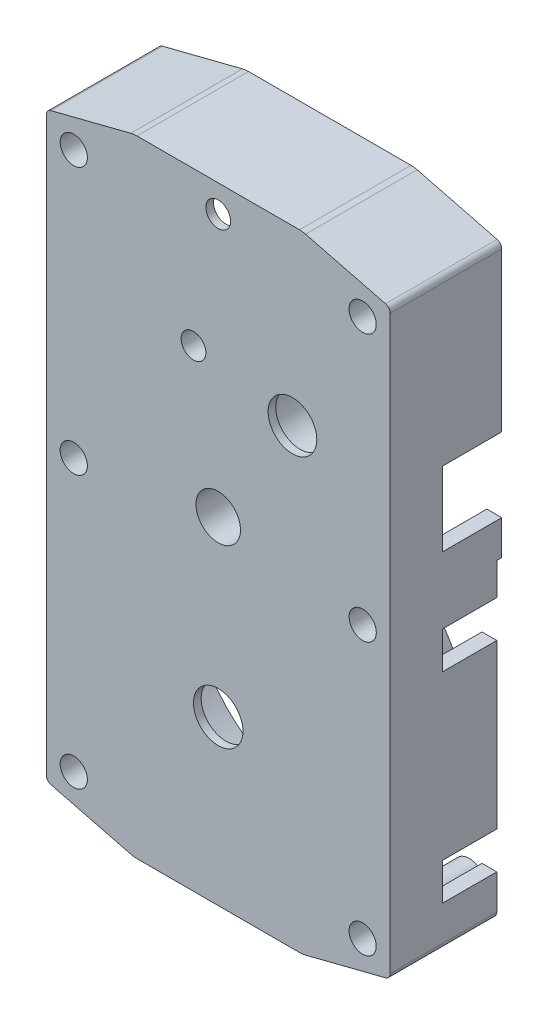
from build123d import *

# Parameters (mm, degrees)
BOSS_EXTRUDE1_DEPTH = 4.51
CUT_EXTRUDE1_DEPTH  = 4.2
SKETCH6_R           = 0.65
BOSS_EXTRUDE2_DEPTH = 4.2
SKETCH7_R           = 0.55
CUT_EXTRUDE2_DEPTH  = 4.6
SKETCH8_R           = 0.5
CUT_EXTRUDE3_DEPTH  = 3.5
SKETCH10_R          = 0.5
SKETCH10_R_2        = 0.985
SKETCH10_R_3        = 0.9
SKETCH10_R_4        = 1
SKETCH10_R_5        = 0.75
CUT_EXTRUDE4_DEPTH  = 10
SKETCH16_W          = 2.4
SKETCH16_H          = 3
SKETCH16_H_2        = 1.5
CUT_EXTRUDE5_DEPTH  = 0.6
SKETCH18_W          = 1.5
SKETCH18_H          = 2.4
CUT_EXTRUDE6_DEPTH  = 1
SKETCH21_W          = 2.4
SKETCH21_H          = 1.5
SKETCH21_W_2        = 1.5
SKETCH21_H_2        = 8.25
CUT_EXTRUDE7_DEPTH  = 0.6
SKETCH22_R          = 1.3
SKETCH22_R_2        = 0.9
BOSS_EXTRUDE3_DEPTH = 4.25
SKETCH23_R          = 5.9
SKETCH23_R_2        = 5.5
BOSS_EXTRUDE4_DEPTH = 4
SKETCH24_R          = 1.6
SKETCH24_R_2        = 1.2
SKETCH24_R_3        = 1.25
SKETCH24_R_4        = 0.5
BOSS_EXTRUDE5_DEPTH = 3.75
SKETCH26_R          = 0.75
BOSS_EXTRUDE6_DEPTH = 4.51
SKETCH27_R          = 0.675
BOSS_EXTRUDE7_DEPTH = 4.6
BOSS_EXTRUDE8_DEPTH = 1.25
SKETCH29_W          = 0.2
SKETCH29_H          = 13.4
CUT_EXTRUDE8_DEPTH  = 15


with BuildPart() as part:
    # Sketch4 → Boss-Extrude1 (new body)
    with BuildSketch(Plane.XY):
        with BuildLine():
            ThreePointArc((-13.711599695, 0.852101617), (-13.847357447, 0.940933533), (-13.9, 1.09439375))
            Line((-13.9, 1.09439375), (-13.9, 24.20560625))
            ThreePointArc((-13.9, 24.20560625), (-13.847357447, 24.359066467), (-13.711599695, 24.447898383))
            Line((-13.711599695, 24.447898383), (-10.481270444, 25.269168531))
            ThreePointArc((-10.481270444, 25.269168531), (-10.359031781, 25.292262196), (-10.234871665, 25.3))
            Line((-10.234871665, 25.3), (-3.665128335, 25.3))
            ThreePointArc((-3.665128335, 25.3), (-3.540968219, 25.292262196), (-3.418729556, 25.269168531))
            Line((-3.418729556, 25.269168531), (-0.188400305, 24.447898383))
            ThreePointArc((-0.188400305, 24.447898383), (-0.052642553, 24.359066467), (0, 24.20560625))
            Line((0, 24.20560625), (0, 1.09439375))
            ThreePointArc((0, 1.09439375), (-0.052642553, 0.940933533), (-0.188400305, 0.852101617))
            Line((-0.188400305, 0.852101617), (-3.418729556, 0.030831469))
            ThreePointArc((-3.418729556, 0.030831469), (-3.540968219, 0.007737804), (-3.665128335, 0))
            Line((-3.665128335, 0), (-10.234871665, 0))
            ThreePointArc((-10.234871665, 0), (-10.359031781, 0.007737804), (-10.481270444, 0.030831469))
            Line((-10.481270444, 0.030831469), (-13.711599695, 0.852101617))
        make_face()
    extrude(amount=BOSS_EXTRUDE1_DEPTH)

    # Sketch5 → Cut-Extrude1 (cut)
    with BuildSketch(Plane(origin=(0, 0, 0), x_dir=(-1, 0, 0), z_dir=(0, 0, -1))):
        with BuildLine():
            Line((13.3, 1.366545), (13.3, 23.933455))
            Line((13.3, 23.933455), (10.333431177, 24.687667412))
            ThreePointArc((10.333431177, 24.687667412), (10.284535712, 24.696904878), (10.234871665, 24.7))
            Line((10.234871665, 24.7), (3.665128335, 24.7))
            ThreePointArc((3.665128335, 24.7), (3.615464288, 24.696904878), (3.566568823, 24.687667412))
            Line((3.566568823, 24.687667412), (0.6, 23.933455))
            Line((0.6, 23.933455), (0.6, 1.366545))
            Line((0.6, 1.366545), (3.566568823, 0.612332588))
            ThreePointArc((3.566568823, 0.612332588), (3.615464288, 0.603095122), (3.665128335, 0.6))
            Line((3.665128335, 0.6), (10.234871665, 0.6))
            ThreePointArc((10.234871665, 0.6), (10.284535712, 0.603095122), (10.333431177, 0.612332588))
            Line((10.333431177, 0.612332588), (13.3, 1.366545))
        make_face()
    extrude(amount=-CUT_EXTRUDE1_DEPTH, mode=Mode.SUBTRACT)

    # Sketch6 → Boss-Extrude2 (add)
    with BuildSketch(Plane(origin=(0, 0, 4.2), x_dir=(-1, 0, 0), z_dir=(0, 0, -1))):
        with Locations((1.112347538, 1.766545)):
            Circle(SKETCH6_R)
        with Locations((1.112347538, 23.533455)):
            Circle(SKETCH6_R)
        with Locations((1.11, 12.75)):
            Circle(SKETCH6_R)
        with Locations((12.787652462, 23.533455)):
            Circle(SKETCH6_R)
        with Locations((12.787652462, 1.766545)):
            Circle(SKETCH6_R)
        with Locations((12.79, 12.75)):
            Circle(SKETCH6_R)
    extrude(amount=BOSS_EXTRUDE2_DEPTH)

    # Sketch7 → Cut-Extrude2 (cut)
    with BuildSketch(Plane(origin=(0, 0, 0), x_dir=(-1, 0, 0), z_dir=(0, 0, -1))):
        with Locations((1.112347538, 1.766545)):
            Circle(SKETCH7_R)
        with Locations((1.11, 12.75)):
            Circle(SKETCH7_R)
        with Locations((1.112347538, 23.533455)):
            Circle(SKETCH7_R)
        with Locations(Location((12.787652462, 1.766545, 0), (0, 0, 180))):
            Circle(SKETCH7_R)
        with Locations(Location((12.787652462, 23.533455, 0), (0, 0, 180))):
            Circle(SKETCH7_R)
        with Locations(Location((12.79, 12.75, 0), (0, 0, 180))):
            Circle(SKETCH7_R)
    extrude(amount=-CUT_EXTRUDE2_DEPTH, mode=Mode.SUBTRACT)

    # Sketch8 → Cut-Extrude3 (cut)
    with BuildSketch(Plane(origin=(0, 0, 4.2), x_dir=(-1, 0, 0), z_dir=(0, 0, -1))):
        with Locations(Location((6.95, 24.2, 0), (0, 0, 90))):
            Circle(SKETCH8_R)
    extrude(amount=-CUT_EXTRUDE3_DEPTH, mode=Mode.SUBTRACT)

    # Sketch10 → Cut-Extrude4 (cut)
    with BuildSketch(Plane.XY.offset(4.51)):
        with Locations((-7.95, 19.1)):
            Circle(SKETCH10_R)
        with Locations((-3.95, 18.3)):
            Circle(SKETCH10_R_2)
        with Locations((-6.95, 13.6)):
            Circle(SKETCH10_R_3)
        with Locations((-6.95, 6.6)):
            Circle(SKETCH10_R_4)
        with Locations((-11.3, 17.35)):
            Circle(SKETCH10_R_5)
    extrude(amount=-CUT_EXTRUDE4_DEPTH, mode=Mode.SUBTRACT)

    # Sketch16 → Cut-Extrude5 (cut)
    with BuildSketch(Plane(origin=(0, 0, 0), x_dir=(0, 0, -1), z_dir=(1, 0, 0))):
        with Locations((-1.2, 16.3)):
            Rectangle(SKETCH16_W, SKETCH16_H)
        with Locations((-1.2, 11.35)):
            Rectangle(SKETCH16_W, SKETCH16_H_2)
        with Locations((-1.2, 3.25)):
            Rectangle(SKETCH16_W, SKETCH16_H_2)
    extrude(amount=-CUT_EXTRUDE5_DEPTH, mode=Mode.SUBTRACT)

    # Sketch18 → Cut-Extrude6 (cut)
    with BuildSketch(Plane(origin=(0, 0, 0), x_dir=(-1, 0, 0), z_dir=(0, -1, 0))):
        with Locations((2.95, -1.2)):
            Rectangle(SKETCH18_W, SKETCH18_H)
        with Locations((11.15, -1.2)):
            Rectangle(SKETCH18_W, SKETCH18_H)
    extrude(amount=-CUT_EXTRUDE6_DEPTH, mode=Mode.SUBTRACT)

    # Sketch21 → Cut-Extrude7 (cut)
    with BuildSketch(Plane.ZY.offset(13.9)):
        with Locations((1.2, 3.25)):
            Rectangle(SKETCH21_W, SKETCH21_H)
        with Locations((1.2, 11.35)):
            Rectangle(SKETCH21_W, SKETCH21_H)
        with Locations((0.75, 18.175)):
            Rectangle(SKETCH21_W_2, SKETCH21_H_2)
    extrude(amount=-CUT_EXTRUDE7_DEPTH, mode=Mode.SUBTRACT)

    # Sketch22 → Boss-Extrude3 (add)
    with BuildSketch(Plane(origin=(0, 0, 4.2), x_dir=(-1, 0, 0), z_dir=(0, 0, -1))):
        with Locations((6.95, 13.6)):
            Circle(SKETCH22_R)
        with Locations(Location((6.95, 13.6, 0), (0, 0, 180))):
            Circle(SKETCH22_R_2, mode=Mode.SUBTRACT)
    extrude(amount=BOSS_EXTRUDE3_DEPTH)

    # Sketch23 → Boss-Extrude4 (add)
    with BuildSketch(Plane(origin=(0, 0, 4.2), x_dir=(-1, 0, 0), z_dir=(0, 0, -1))):
        with Locations((6.95, 6.6)):
            Circle(SKETCH23_R)
        with Locations((6.95, 6.6)):
            Circle(SKETCH23_R_2, mode=Mode.SUBTRACT)
    extrude(amount=BOSS_EXTRUDE4_DEPTH)

    # Sketch24 → Boss-Extrude5 (add)
    with BuildSketch(Plane(origin=(0, 0, 4.2), x_dir=(-1, 0, 0), z_dir=(0, 0, -1))):
        with Locations((3.95, 18.3)):
            Circle(SKETCH24_R)
        with Locations((3.95, 18.3)):
            Circle(SKETCH24_R_2, mode=Mode.SUBTRACT)
        with Locations((7.95, 19.1)):
            Circle(SKETCH24_R_3)
        with Locations(Location((7.95, 19.1, 0), (0, 0, 180))):
            Circle(SKETCH24_R_4, mode=Mode.SUBTRACT)
    extrude(amount=BOSS_EXTRUDE5_DEPTH)

    # Sketch26 → Boss-Extrude6 (add)
    with BuildSketch(Plane.XY.offset(4.51)):
        with Locations((-11.3, 17.35)):
            Circle(SKETCH26_R)
    extrude(amount=-BOSS_EXTRUDE6_DEPTH)

    # Sketch27 → Boss-Extrude7 (add)
    with BuildSketch(Plane(origin=(0, 0, 0), x_dir=(-1, 0, 0), z_dir=(0, 0, -1))):
        with Locations((11.3, 17.35)):
            Circle(SKETCH27_R)
    extrude(amount=BOSS_EXTRUDE7_DEPTH)

    # Sketch28 → Boss-Extrude8 (add)
    with BuildSketch(Plane(origin=(0, 0, 0.45), x_dir=(-1, 0, 0), z_dir=(0, 0, -1))):
        with BuildLine():
            ThreePointArc((7.737135239, 20.331742097), (9.19542716, 19.206823169), (7.95, 17.85))
            ThreePointArc((7.95, 17.85), (7.865931561, 17.934068439), (7.95, 18.018136879))
            ThreePointArc((7.95, 18.018136879), (9.02656312, 19.206956355), (7.737135239, 20.160715045))
            ThreePointArc((7.737135239, 20.160715045), (7.728639485, 20.246228571), (7.737135239, 20.331742097))
        make_face()
    extrude(amount=BOSS_EXTRUDE8_DEPTH)

    # Sketch29 → Cut-Extrude8 (cut)
    with BuildSketch(Plane(origin=(0, 0, 0), x_dir=(0, 0, -1), z_dir=(1, 0, 0))):
        with Locations((-0.1, 6.7)):
            Rectangle(SKETCH29_W, SKETCH29_H)
    extrude(amount=-CUT_EXTRUDE8_DEPTH, mode=Mode.SUBTRACT)


solid = part.part
